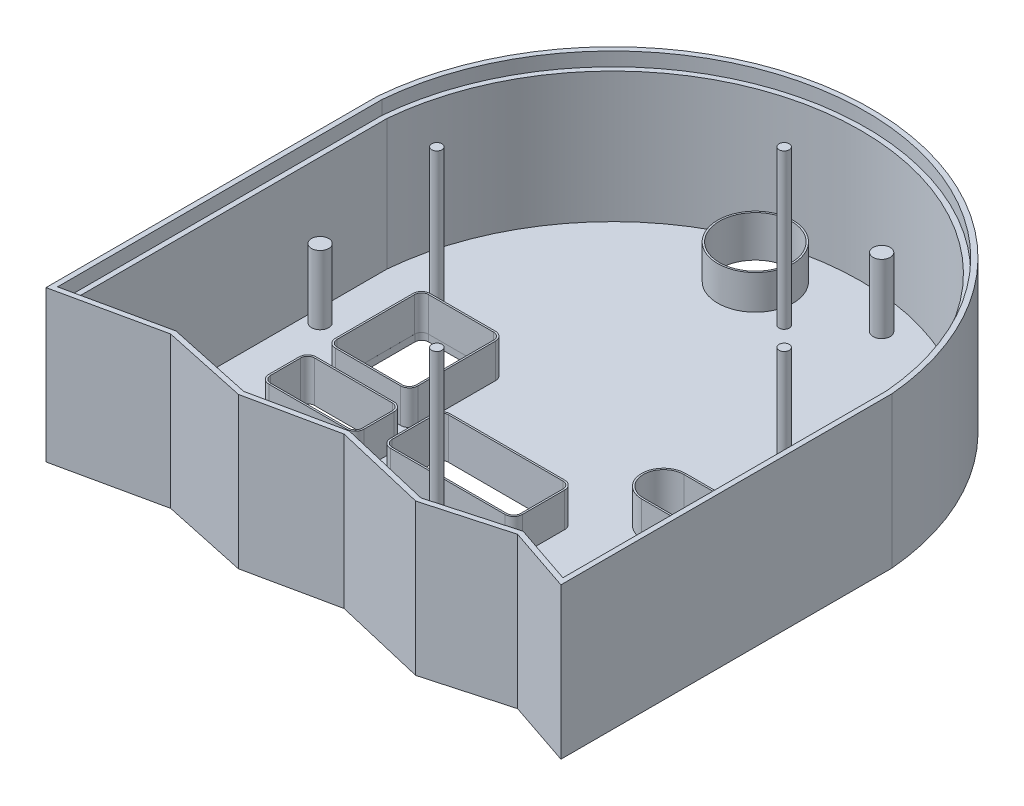
from build123d import *

# Parameters (mm, degrees)
SKETCH2_R             = 1.5
BOSS_EXTRUDE1_DEPTH   = 47
BOSS_EXTRUDE1_2_DEPTH = 47
BOSS_EXTRUDE1_3_DEPTH = 47
BOSS_EXTRUDE1_4_DEPTH = 47
BOSS_EXTRUDE3_DEPTH   = 2
SKETCH4_R             = 10.46
CUT_EXTRUDE1_DEPTH    = 3
BOSS_EXTRUDE4_DEPTH   = 42
SKETCH6_R             = 2.5
BOSS_EXTRUDE5_DEPTH   = 20
CUT_EXTRUDE3_DEPTH    = 4
SKETCH9_R             = 6.5
CUT_EXTRUDE4_DEPTH    = 3
SKETCH11_R            = 10.96
SKETCH11_R_2          = 10.46
BOSS_EXTRUDE9_DEPTH   = 10


with BuildPart() as part:
    # Sketch2 → Boss-Extrude1 (new body)
    with BuildSketch(Plane(origin=(0, 0, 0), x_dir=(1, 0, 0), z_dir=(0, 1, 0))):
        with Locations((0, 50.59)):
            Circle(SKETCH2_R)
    extrude(amount=BOSS_EXTRUDE1_DEPTH)



with BuildPart() as body_2:
    # Sketch2 → Boss-Extrude1 2 (new body)
    with BuildSketch(Plane(origin=(0, 0, 0), x_dir=(1, 0, 0), z_dir=(0, 1, 0))):
        with Locations((0, -50.59)):
            Circle(SKETCH2_R)
    extrude(amount=BOSS_EXTRUDE1_2_DEPTH)


with BuildPart() as body_3:
    # Sketch2 → Boss-Extrude1 3 (new body)
    with BuildSketch(Plane(origin=(0, 0, 0), x_dir=(1, 0, 0), z_dir=(0, 1, 0))):
        with Locations((-50.59, 0)):
            Circle(SKETCH2_R)
    extrude(amount=BOSS_EXTRUDE1_3_DEPTH)


with BuildPart() as body_4:
    # Sketch2 → Boss-Extrude1 4 (new body)
    with BuildSketch(Plane(origin=(0, 0, 0), x_dir=(1, 0, 0), z_dir=(0, 1, 0))):
        with Locations((50.59, 0)):
            Circle(SKETCH2_R)
    extrude(amount=BOSS_EXTRUDE1_4_DEPTH)


with BuildPart() as part_1:
    add(part.part)

    add(body_2.part)  # Boss-Extrude3 merges body 2

    add(body_3.part)  # Boss-Extrude3 merges body 3

    add(body_4.part)  # Boss-Extrude3 merges body 4
    # Sketch3 → Boss-Extrude3 (add)
    with BuildSketch(Plane(origin=(0, 0, 0), x_dir=(1, 0, 0), z_dir=(0, 1, 0))):
        with BuildLine():
            Line((-75, -83), (-75, -89.4475393))
            Line((-75, -89.4475393), (-45.125382539, -83))
            Line((-45.125382539, -83), (-20.02947887, -88.373917753))
            Line((-20.02947887, -88.373917753), (5.401931533, -83))
            Line((5.401931533, -83), (32.712179644, -89.4475393))
            Line((32.712179644, -89.4475393), (55.929245606, -83))
            Line((55.929245606, -83), (75, -89.4475393))
            Line((75, -89.4475393), (75, -83))
            Line((75, -83), (75, 7))
            ThreePointArc((75, 7), (0, 75.884515459), (-75, 7))
            Line((-75, 7), (-75, -83))
        make_face()
    extrude(amount=BOSS_EXTRUDE3_DEPTH)

    # Sketch4 → Cut-Extrude1 (cut, through all)
    with BuildSketch(Plane(origin=(0, 2, 0), x_dir=(1, 0, 0), z_dir=(0, 1, 0))):
        with Locations((-15.202971328, 57.401455548)):
            Circle(SKETCH4_R)
        with BuildLine():
            Line((-30.526931119, -3.452057515), (-49.546447337, -3.452057515))
            ThreePointArc((-49.546447337, -3.452057515), (-50.960660899, -4.037843953), (-51.546447337, -5.452057515))
            Line((-51.546447337, -5.452057515), (-51.546447337, -28.03739889))
            ThreePointArc((-51.546447337, -28.03739889), (-50.960660899, -29.451612453), (-49.546447337, -30.03739889))
            Line((-49.546447337, -30.03739889), (-30.526931119, -30.03739889))
            ThreePointArc((-30.526931119, -30.03739889), (-29.112717557, -29.451612453), (-28.526931119, -28.03739889))
            Line((-28.526931119, -28.03739889), (-28.526931119, -21.640436784))
            Line((-28.526931119, -21.640436784), (-28.526931119, -5.452057515))
            ThreePointArc((-28.526931119, -5.452057515), (-29.112717557, -4.037843953), (-30.526931119, -3.452057515))
        make_face()
        with BuildLine():
            Line((-50.146859919, -36.095300142), (-27.470865471, -36.095300142))
            ThreePointArc((-27.470865471, -36.095300142), (-26.056651908, -36.681086579), (-25.470865471, -38.095300142))
            Line((-25.470865471, -38.095300142), (-25.470865471, -46.854222448))
            ThreePointArc((-25.470865471, -46.854222448), (-26.056651908, -48.26843601), (-27.470865471, -48.854222448))
            Line((-27.470865471, -48.854222448), (-50.146859919, -48.854222448))
            ThreePointArc((-50.146859919, -48.854222448), (-51.561073481, -48.26843601), (-52.146859919, -46.854222448))
            Line((-52.146859919, -46.854222448), (-52.146859919, -38.095300142))
            ThreePointArc((-52.146859919, -38.095300142), (-51.561073481, -36.681086579), (-50.146859919, -36.095300142))
        make_face()
        with BuildLine():
            Line((33.06, -11.685874323), (43.06, -11.685874323))
            ThreePointArc((43.06, -11.685874323), (48.972240648, -17.598114971), (43.06, -23.510355619))
            Line((43.06, -23.510355619), (33.06, -23.510355619))
            ThreePointArc((33.06, -23.510355619), (27.147759352, -17.598114971), (33.06, -11.685874323))
        make_face()
        with BuildLine():
            Line((-18.29793306, -32.920143934), (-18.29793306, -45.313819663))
            ThreePointArc((-18.29793306, -45.313819663), (-17.712146622, -46.728033226), (-16.29793306, -47.313819663))
            Line((-16.29793306, -47.313819663), (17.12131177, -47.313819663))
            ThreePointArc((17.12131177, -47.313819663), (18.535525332, -46.728033226), (19.12131177, -45.313819663))
            Line((19.12131177, -45.313819663), (19.12131177, -32.961376992))
            ThreePointArc((19.12131177, -32.961376992), (18.536397499, -31.548036135), (17.123779391, -30.961378514))
            Line((17.123779391, -30.961378514), (-16.295465438, -30.920145456))
            ThreePointArc((-16.295465438, -30.920145456), (-17.711273917, -31.505058204), (-18.29793306, -32.920143934))
        make_face()
    extrude(amount=-CUT_EXTRUDE1_DEPTH, mode=Mode.SUBTRACT)

    # Sketch5 → Boss-Extrude4 (add)
    with BuildSketch(Plane(origin=(0, 2, 0), x_dir=(1, 0, 0), z_dir=(0, 1, 0))):
        with BuildLine():
            Line((-75, -89.4475393), (-45.125382539, -83))
            Line((-45.125382539, -83), (-20.02947887, -88.373917753))
            Line((-20.02947887, -88.373917753), (5.401931533, -83))
            Line((5.401931533, -83), (32.712179644, -89.4475393))
            Line((32.712179644, -89.4475393), (55.929245606, -83))
            Line((55.929245606, -83), (75, -89.4475393))
            Line((75, -89.4475393), (75, 7))
            ThreePointArc((75, 7), (0, 75.884515459), (-75, 7))
            Line((-75, 7), (-75, -89.4475393))
        make_face()
        with BuildLine():
            Line((-72, -85.731007132), (-45.127853177, -79.93146098))
            Line((-45.127853177, -79.93146098), (-20.025334108, -85.306795323))
            Line((-20.025334108, -85.306795323), (5.438194792, -79.926090603))
            Line((5.438194792, -79.926090603), (32.651721765, -86.350795495))
            Line((32.651721765, -86.350795495), (56.015770192, -79.862438151))
            Line((56.015770192, -79.862438151), (72, -85.266469252))
            Line((72, -85.266469252), (72, 6.871192973))
            ThreePointArc((72, 6.871192973), (0, 72.884515459), (-72, 6.871192973))
            Line((-72, 6.871192973), (-72, -85.731007132))
        make_face(mode=Mode.SUBTRACT)
    extrude(amount=BOSS_EXTRUDE4_DEPTH)

    # Sketch6 → Boss-Extrude5 (add)
    with BuildSketch(Plane(origin=(0, 2, 0), x_dir=(1, 0, 0), z_dir=(0, 1, 0))):
        with Locations((60.646848442, -72.794584312)):
            Circle(SKETCH6_R)
        with Locations((-68.18605967, -16.404812448)):
            Circle(SKETCH6_R)
        with Locations((15.843137374, 63.149755735)):
            Circle(SKETCH6_R)
    extrude(amount=BOSS_EXTRUDE5_DEPTH)

    # Sketch8 → Cut-Extrude3 (cut)
    with BuildSketch(Plane(origin=(0, 44, 0), x_dir=(1, 0, 0), z_dir=(0, 1, 0))):
        with BuildLine():
            Line((-73.5, -87.589273216), (-45.126617858, -81.46573049))
            Line((-45.126617858, -81.46573049), (-20.027406489, -86.840356538))
            Line((-20.027406489, -86.840356538), (5.420063162, -81.463045301))
            Line((5.420063162, -81.463045301), (32.681950704, -87.899167398))
            Line((32.681950704, -87.899167398), (55.972507899, -81.431219076))
            Line((55.972507899, -81.431219076), (73.5, -87.357004276))
            Line((73.5, -87.357004276), (73.5, 6.935924496))
            ThreePointArc((73.5, 6.935924496), (0, 74.384515459), (-73.5, 6.935924496))
            Line((-73.5, 6.935924496), (-73.5, -87.589273216))
        make_face()
        with BuildLine():
            Line((56.015770192, -79.862438151), (72, -85.266469252))
            Line((72, -85.266469252), (72, 6.871192973))
            ThreePointArc((72, 6.871192973), (0, 72.884515459), (-72, 6.871192973))
            Line((-72, 6.871192973), (-72, -85.731007132))
            Line((-72, -85.731007132), (-45.127853177, -79.93146098))
            Line((-45.127853177, -79.93146098), (-20.025334108, -85.306795323))
            Line((-20.025334108, -85.306795323), (5.438194792, -79.926090603))
            Line((5.438194792, -79.926090603), (32.651721765, -86.350795495))
            Line((32.651721765, -86.350795495), (56.015770192, -79.862438151))
        make_face(mode=Mode.SUBTRACT)
    extrude(amount=-CUT_EXTRUDE3_DEPTH, mode=Mode.SUBTRACT)

    # Sketch9 → Cut-Extrude4 (cut, through all)
    with BuildSketch(Plane(origin=(0, 2, 0), x_dir=(1, 0, 0), z_dir=(0, 1, 0))):
        with Locations((32.570848009, -77.226464083)):
            Circle(SKETCH9_R)
    extrude(amount=-CUT_EXTRUDE4_DEPTH, mode=Mode.SUBTRACT)

    # Sketch11 → Boss-Extrude9 (add)
    with BuildSketch(Plane(origin=(0, 2, 0), x_dir=(1, 0, 0), z_dir=(0, 1, 0))):
        with Locations((-15.202971328, 57.401455548)):
            Circle(SKETCH11_R)
        with Locations((-15.202971328, 57.401455548)):
            Circle(SKETCH11_R_2, mode=Mode.SUBTRACT)
        with BuildLine():
            Line((-49.550887282, -30.578607071), (-30.531371065, -30.578607071))
            ThreePointArc((-30.531371065, -30.578607071), (-28.763604112, -29.846374024), (-28.031371065, -28.078607071))
            Line((-28.031371065, -28.078607071), (-28.031371065, -5.493265696))
            ThreePointArc((-28.031371065, -5.493265696), (-28.763604112, -3.725498743), (-30.531371065, -2.993265696))
            Line((-30.531371065, -2.993265696), (-49.550887282, -2.993265696))
            ThreePointArc((-49.550887282, -2.993265696), (-51.318654235, -3.725498743), (-52.050887282, -5.493265696))
            Line((-52.050887282, -5.493265696), (-52.050887282, -28.078607071))
            ThreePointArc((-52.050887282, -28.078607071), (-51.318654235, -29.846374024), (-49.550887282, -30.578607071))
        make_face()
        with BuildLine():
            Line((-49.550887282, -30.078607071), (-30.531371065, -30.078607071))
            ThreePointArc((-30.531371065, -30.078607071), (-29.117157502, -29.492820634), (-28.531371065, -28.078607071))
            Line((-28.531371065, -28.078607071), (-28.531371065, -5.493265696))
            ThreePointArc((-28.531371065, -5.493265696), (-29.117157502, -4.079052134), (-30.531371065, -3.493265696))
            Line((-30.531371065, -3.493265696), (-49.550887282, -3.493265696))
            ThreePointArc((-49.550887282, -3.493265696), (-50.965100845, -4.079052134), (-51.550887282, -5.493265696))
            Line((-51.550887282, -5.493265696), (-51.550887282, -28.078607071))
            ThreePointArc((-51.550887282, -28.078607071), (-50.965100845, -29.492820634), (-49.550887282, -30.078607071))
        make_face(mode=Mode.SUBTRACT)
        with BuildLine():
            Line((-50.146859919, -49.354222448), (-27.470865471, -49.354222448))
            ThreePointArc((-27.470865471, -49.354222448), (-25.703098518, -48.621989401), (-24.970865471, -46.854222448))
            Line((-24.970865471, -46.854222448), (-24.970865471, -38.095300142))
            ThreePointArc((-24.970865471, -38.095300142), (-25.703098518, -36.327533189), (-27.470865471, -35.595300142))
            Line((-27.470865471, -35.595300142), (-50.146859919, -35.595300142))
            ThreePointArc((-50.146859919, -35.595300142), (-51.914626872, -36.327533189), (-52.646859919, -38.095300142))
            Line((-52.646859919, -38.095300142), (-52.646859919, -46.854222448))
            ThreePointArc((-52.646859919, -46.854222448), (-51.914626872, -48.621989401), (-50.146859919, -49.354222448))
        make_face()
        with BuildLine():
            Line((-50.146859919, -48.854222448), (-27.470865471, -48.854222448))
            ThreePointArc((-27.470865471, -48.854222448), (-26.056651908, -48.26843601), (-25.470865471, -46.854222448))
            Line((-25.470865471, -46.854222448), (-25.470865471, -38.095300142))
            ThreePointArc((-25.470865471, -38.095300142), (-26.056651908, -36.681086579), (-27.470865471, -36.095300142))
            Line((-27.470865471, -36.095300142), (-50.146859919, -36.095300142))
            ThreePointArc((-50.146859919, -36.095300142), (-51.561073481, -36.681086579), (-52.146859919, -38.095300142))
            Line((-52.146859919, -38.095300142), (-52.146859919, -46.854222448))
            ThreePointArc((-52.146859919, -46.854222448), (-51.561073481, -48.26843601), (-50.146859919, -48.854222448))
        make_face(mode=Mode.SUBTRACT)
        with BuildLine():
            Line((-18.79793306, -32.920143934), (-18.79793306, -45.313819663))
            ThreePointArc((-18.79793306, -45.313819663), (-18.065700013, -47.081586616), (-16.29793306, -47.813819663))
            Line((-16.29793306, -47.813819663), (17.12131177, -47.813819663))
            ThreePointArc((17.12131177, -47.813819663), (18.889078723, -47.081586616), (19.62131177, -45.313819663))
            Line((19.62131177, -45.313819663), (19.62131177, -32.961376992))
            ThreePointArc((19.62131177, -32.961376992), (18.890168931, -31.19470092), (17.124396297, -30.461378895))
            Line((17.124396297, -30.461378895), (-16.294848533, -30.420145836))
            ThreePointArc((-16.294848533, -30.420145836), (-18.064609131, -31.151286772), (-18.79793306, -32.920143934))
        make_face()
        with BuildLine():
            Line((-18.29793306, -32.920143934), (-18.29793306, -45.313819663))
            ThreePointArc((-18.29793306, -45.313819663), (-17.712146622, -46.728033226), (-16.29793306, -47.313819663))
            Line((-16.29793306, -47.313819663), (17.12131177, -47.313819663))
            ThreePointArc((17.12131177, -47.313819663), (18.535525332, -46.728033226), (19.12131177, -45.313819663))
            Line((19.12131177, -45.313819663), (19.12131177, -32.961376992))
            ThreePointArc((19.12131177, -32.961376992), (18.536397499, -31.548036135), (17.123779391, -30.961378514))
            Line((17.123779391, -30.961378514), (-16.295465438, -30.920145456))
            ThreePointArc((-16.295465438, -30.920145456), (-17.711273917, -31.505058204), (-18.29793306, -32.920143934))
        make_face(mode=Mode.SUBTRACT)
        with BuildLine():
            Line((33.06, -24.010355619), (43.06, -24.010355619))
            ThreePointArc((43.06, -24.010355619), (49.472240648, -17.598114971), (43.06, -11.185874323))
            Line((43.06, -11.185874323), (33.06, -11.185874323))
            ThreePointArc((33.06, -11.185874323), (26.647759352, -17.598114971), (33.06, -24.010355619))
        make_face()
        with BuildLine():
            Line((33.06, -23.510355619), (43.06, -23.510355619))
            ThreePointArc((43.06, -23.510355619), (48.972240648, -17.598114971), (43.06, -11.685874323))
            Line((43.06, -11.685874323), (33.06, -11.685874323))
            ThreePointArc((33.06, -11.685874323), (27.147759352, -17.598114971), (33.06, -23.510355619))
        make_face(mode=Mode.SUBTRACT)
    extrude(amount=BOSS_EXTRUDE9_DEPTH)


solid = part_1.part
